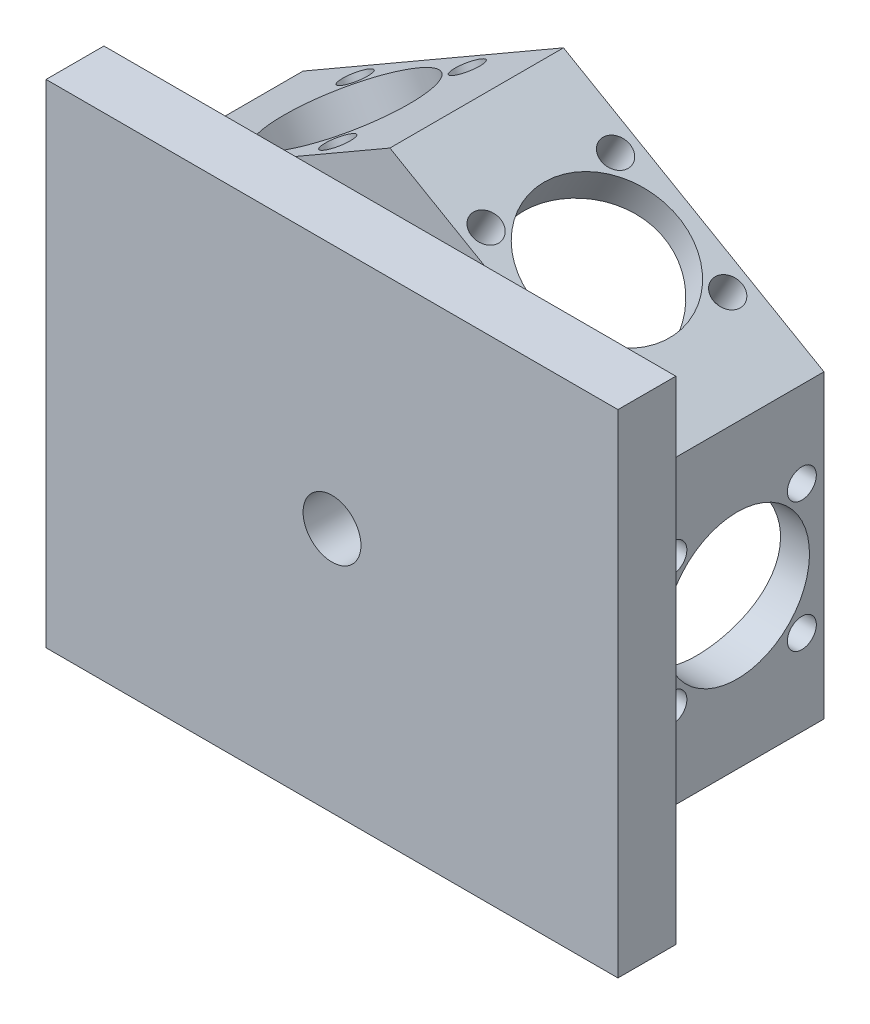
from build123d import *

# Parameters (mm, degrees)
SKETCH1_R                    = 40
BOSS_EXTRUDE1_DEPTH          = 30
SKETCH2_R                    = 2.5
CUT_EXTRUDE1_DEPTH           = 30
SKETCH3_R                    = 12.5
CUT_EXTRUDE2_DEPTH           = 10
CIRPATTERN1_COUNT            = 4
CIRPATTERN2_COUNT            = 6
CIRPATTERN2_COPY_1_SKETCH_R  = 2.5
CIRPATTERN2_COPY_1_DEPTH     = 30
CIRPATTERN2_COPY_2_SKETCH_R  = 2.5
CIRPATTERN2_COPY_2_DEPTH     = 30
CIRPATTERN2_COPY_3_SKETCH_R  = 2.5
CIRPATTERN2_COPY_3_DEPTH     = 30
CIRPATTERN2_COPY_4_SKETCH_R  = 2.5
CIRPATTERN2_COPY_4_DEPTH     = 30
CIRPATTERN2_COPY_5_SKETCH_R  = 2.5
CIRPATTERN2_COPY_5_DEPTH     = 30
CIRPATTERN2_COPY_6_SKETCH_R  = 2.5
CIRPATTERN2_COPY_6_DEPTH     = 30
CIRPATTERN2_COPY_7_SKETCH_R  = 2.5
CIRPATTERN2_COPY_7_DEPTH     = 30
CIRPATTERN2_COPY_8_SKETCH_R  = 2.5
CIRPATTERN2_COPY_8_DEPTH     = 30
CIRPATTERN2_COPY_9_SKETCH_R  = 2.5
CIRPATTERN2_COPY_9_DEPTH     = 30
CIRPATTERN2_COPY_10_SKETCH_R = 2.5
CIRPATTERN2_COPY_10_DEPTH    = 30
CIRPATTERN2_COPY_11_SKETCH_R = 2.5
CIRPATTERN2_COPY_11_DEPTH    = 30
CIRPATTERN2_COPY_12_SKETCH_R = 2.5
CIRPATTERN2_COPY_12_DEPTH    = 30
CIRPATTERN2_COPY_13_SKETCH_R = 2.5
CIRPATTERN2_COPY_13_DEPTH    = 30
CIRPATTERN2_COPY_14_SKETCH_R = 2.5
CIRPATTERN2_COPY_14_DEPTH    = 30
CIRPATTERN2_COPY_15_SKETCH_R = 2.5
CIRPATTERN2_COPY_15_DEPTH    = 30
SKETCH4_W                    = 98.815097152
SKETCH4_H                    = 85.054179918
SKETCH4_R                    = 5
BOSS_EXTRUDE2_DEPTH          = 10


with BuildPart() as part:
    # Sketch1 → Boss-Extrude1 (new body)
    with BuildSketch(Plane.XY):
        Polygon((0, -51.961524227), (45, -25.980762114), (45, 25.980762114), (0, 51.961524227), (-45, 25.980762114), (-45, -25.980762114), align=None)
        Circle(SKETCH1_R, mode=Mode.SUBTRACT)
    extrude(amount=BOSS_EXTRUDE1_DEPTH)

    # Sketch2 → Cut-Extrude1 (cut)
    with BuildSketch(Plane(origin=(22.5, 38.97114317, 0), x_dir=(0.866025404, -0.5, 0), z_dir=(0.5, 0.866025404, 0))):
        with Locations((-11.186429278, -3.813570722)):
            Circle(SKETCH2_R)
    cut_extrude1 = extrude(amount=-CUT_EXTRUDE1_DEPTH, mode=Mode.SUBTRACT)

    # Sketch3 → Cut-Extrude2 (cut)
    with BuildSketch(Plane(origin=(22.5, 38.97114317, 0), x_dir=(0.866025404, -0.5, 0), z_dir=(0.5, 0.866025404, 0))):
        with Locations((0, -15)):
            Circle(SKETCH3_R)
    cut_extrude2 = extrude(amount=-CUT_EXTRUDE2_DEPTH, mode=Mode.SUBTRACT)

    # CirPattern1: Cut-Extrude1 ×4 about axis
    cirpattern1_axis = Axis((0, 0, 15), (0.5, 0.866025404, 0))
    for i in range(1, CIRPATTERN1_COUNT):
        add(cut_extrude1.rotate(cirpattern1_axis, i * 360 / CIRPATTERN1_COUNT), mode=Mode.SUBTRACT)

    # CirPattern2: Cut-Extrude2, Cut-Extrude1 ×6 about axis
    cirpattern2_axis = Axis((0, 0, 30), (0, 0, 1))
    for i in range(1, CIRPATTERN2_COUNT):
        add(cut_extrude2.rotate(cirpattern2_axis, i * 360 / CIRPATTERN2_COUNT), mode=Mode.SUBTRACT)
        add(cut_extrude1.rotate(cirpattern2_axis, i * 360 / CIRPATTERN2_COUNT), mode=Mode.SUBTRACT)

    # CirPattern2 copy 1 sketch → CirPattern2 copy 1 (cut)
    with BuildSketch(Plane(origin=(-35.490381057, 31.47114317, 15), x_dir=(0, 0, -1), z_dir=(-0.5, 0.866025404, 0))):
        with Locations((-11.186429278, -3.813570722)):
            Circle(CIRPATTERN2_COPY_1_SKETCH_R)
    extrude(amount=-CIRPATTERN2_COPY_1_DEPTH, mode=Mode.SUBTRACT)

    # CirPattern2 copy 2 sketch → CirPattern2 copy 2 (cut)
    with BuildSketch(Plane(origin=(-45, -15, 15), x_dir=(0, 0, -1), z_dir=(-1, 0, 0))):
        with Locations((-11.186429278, -3.813570722)):
            Circle(CIRPATTERN2_COPY_2_SKETCH_R)
    extrude(amount=-CIRPATTERN2_COPY_2_DEPTH, mode=Mode.SUBTRACT)

    # CirPattern2 copy 3 sketch → CirPattern2 copy 3 (cut)
    with BuildSketch(Plane(origin=(-9.509618943, -46.47114317, 15), x_dir=(0, 0, -1), z_dir=(-0.5, -0.866025404, 0))):
        with Locations((-11.186429278, -3.813570722)):
            Circle(CIRPATTERN2_COPY_3_SKETCH_R)
    extrude(amount=-CIRPATTERN2_COPY_3_DEPTH, mode=Mode.SUBTRACT)

    # CirPattern2 copy 4 sketch → CirPattern2 copy 4 (cut)
    with BuildSketch(Plane(origin=(35.490381057, -31.47114317, 15), x_dir=(0, 0, -1), z_dir=(0.5, -0.866025404, 0))):
        with Locations((-11.186429278, -3.813570722)):
            Circle(CIRPATTERN2_COPY_4_SKETCH_R)
    extrude(amount=-CIRPATTERN2_COPY_4_DEPTH, mode=Mode.SUBTRACT)

    # CirPattern2 copy 5 sketch → CirPattern2 copy 5 (cut)
    with BuildSketch(Plane(origin=(45, 15, 15), x_dir=(0, 0, -1), z_dir=(1, 0, 0))):
        with Locations((-11.186429278, -3.813570722)):
            Circle(CIRPATTERN2_COPY_5_SKETCH_R)
    extrude(amount=-CIRPATTERN2_COPY_5_DEPTH, mode=Mode.SUBTRACT)

    # CirPattern2 copy 6 sketch → CirPattern2 copy 6 (cut)
    with BuildSketch(Plane(origin=(-22.5, 38.97114317, 30), x_dir=(-0.866025404, -0.5, 0), z_dir=(-0.5, 0.866025404, 0))):
        with Locations((-11.186429278, -3.813570722)):
            Circle(CIRPATTERN2_COPY_6_SKETCH_R)
    extrude(amount=-CIRPATTERN2_COPY_6_DEPTH, mode=Mode.SUBTRACT)

    # CirPattern2 copy 7 sketch → CirPattern2 copy 7 (cut)
    with BuildSketch(Plane(origin=(-45, 0, 30), x_dir=(0, -1, 0), z_dir=(-1, 0, 0))):
        with Locations((-11.186429278, -3.813570722)):
            Circle(CIRPATTERN2_COPY_7_SKETCH_R)
    extrude(amount=-CIRPATTERN2_COPY_7_DEPTH, mode=Mode.SUBTRACT)

    # CirPattern2 copy 8 sketch → CirPattern2 copy 8 (cut)
    with BuildSketch(Plane(origin=(-22.5, -38.97114317, 30), x_dir=(0.866025404, -0.5, 0), z_dir=(-0.5, -0.866025404, 0))):
        with Locations((-11.186429278, -3.813570722)):
            Circle(CIRPATTERN2_COPY_8_SKETCH_R)
    extrude(amount=-CIRPATTERN2_COPY_8_DEPTH, mode=Mode.SUBTRACT)

    # CirPattern2 copy 9 sketch → CirPattern2 copy 9 (cut)
    with BuildSketch(Plane(origin=(22.5, -38.97114317, 30), x_dir=(0.866025404, 0.5, 0), z_dir=(0.5, -0.866025404, 0))):
        with Locations((-11.186429278, -3.813570722)):
            Circle(CIRPATTERN2_COPY_9_SKETCH_R)
    extrude(amount=-CIRPATTERN2_COPY_9_DEPTH, mode=Mode.SUBTRACT)

    # CirPattern2 copy 10 sketch → CirPattern2 copy 10 (cut)
    with BuildSketch(Plane(origin=(45, 0, 30), x_dir=(0, 1, 0), z_dir=(1, 0, 0))):
        with Locations((-11.186429278, -3.813570722)):
            Circle(CIRPATTERN2_COPY_10_SKETCH_R)
    extrude(amount=-CIRPATTERN2_COPY_10_DEPTH, mode=Mode.SUBTRACT)

    # CirPattern2 copy 11 sketch → CirPattern2 copy 11 (cut)
    with BuildSketch(Plane(origin=(-9.509618943, 46.47114317, 15), x_dir=(0, 0, 1), z_dir=(-0.5, 0.866025404, 0))):
        with Locations((-11.186429278, -3.813570722)):
            Circle(CIRPATTERN2_COPY_11_SKETCH_R)
    extrude(amount=-CIRPATTERN2_COPY_11_DEPTH, mode=Mode.SUBTRACT)

    # CirPattern2 copy 12 sketch → CirPattern2 copy 12 (cut)
    with BuildSketch(Plane(origin=(-45, 15, 15), x_dir=(0, 0, 1), z_dir=(-1, 0, 0))):
        with Locations((-11.186429278, -3.813570722)):
            Circle(CIRPATTERN2_COPY_12_SKETCH_R)
    extrude(amount=-CIRPATTERN2_COPY_12_DEPTH, mode=Mode.SUBTRACT)

    # CirPattern2 copy 13 sketch → CirPattern2 copy 13 (cut)
    with BuildSketch(Plane(origin=(-35.490381057, -31.47114317, 15), x_dir=(0, 0, 1), z_dir=(-0.5, -0.866025404, 0))):
        with Locations((-11.186429278, -3.813570722)):
            Circle(CIRPATTERN2_COPY_13_SKETCH_R)
    extrude(amount=-CIRPATTERN2_COPY_13_DEPTH, mode=Mode.SUBTRACT)

    # CirPattern2 copy 14 sketch → CirPattern2 copy 14 (cut)
    with BuildSketch(Plane(origin=(9.509618943, -46.47114317, 15), x_dir=(0, 0, 1), z_dir=(0.5, -0.866025404, 0))):
        with Locations((-11.186429278, -3.813570722)):
            Circle(CIRPATTERN2_COPY_14_SKETCH_R)
    extrude(amount=-CIRPATTERN2_COPY_14_DEPTH, mode=Mode.SUBTRACT)

    # CirPattern2 copy 15 sketch → CirPattern2 copy 15 (cut)
    with BuildSketch(Plane(origin=(45, -15, 15), x_dir=(0, 0, 1), z_dir=(1, 0, 0))):
        with Locations((-11.186429278, -3.813570722)):
            Circle(CIRPATTERN2_COPY_15_SKETCH_R)
    extrude(amount=-CIRPATTERN2_COPY_15_DEPTH, mode=Mode.SUBTRACT)

    # Sketch4 → Boss-Extrude2 (add)
    with BuildSketch(Plane.XY.offset(30)):
        Rectangle(SKETCH4_W, SKETCH4_H)
        Circle(SKETCH4_R, mode=Mode.SUBTRACT)
    extrude(amount=BOSS_EXTRUDE2_DEPTH)


solid = part.part
